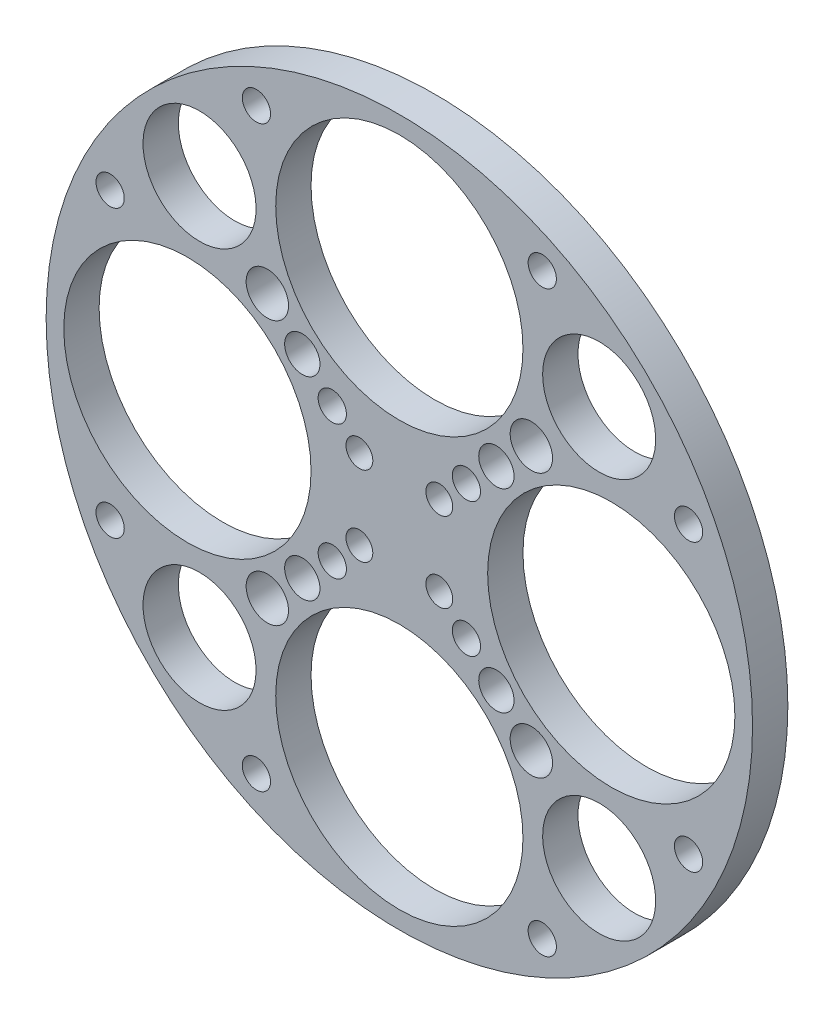
from build123d import *

# Parameters (mm, degrees)
SKETCH1_R           = 50
BOSS_EXTRUDE1_DEPTH = 5
SKETCH2_R           = 1.9
CUT_EXTRUDE1_DEPTH  = 6
CIRPATTERN1_COUNT   = 4
SKETCH3_R           = 17.5
CUT_EXTRUDE2_DEPTH  = 6
CIRPATTERN2_COUNT   = 4
SKETCH4_R           = 8
SKETCH4_R_2         = 3
SKETCH4_R_3         = 2.5
SKETCH4_R_4         = 2
CUT_EXTRUDE3_DEPTH  = 6
CIRPATTERN3_COUNT   = 4


with BuildPart() as part:
    # Sketch1 → Boss-Extrude1 (new body)
    with BuildSketch(Plane.XY):
        Circle(SKETCH1_R)
    extrude(amount=BOSS_EXTRUDE1_DEPTH)

    # Sketch2 → Cut-Extrude1 (cut, through all)
    with BuildSketch(Plane(origin=(0, 0, 0), x_dir=(-1, 0, 0), z_dir=(0, 0, -1))):
        with Locations((-5.656854249, 5.656854249)):
            Circle(SKETCH2_R)
    cut_extrude1 = extrude(amount=-CUT_EXTRUDE1_DEPTH, mode=Mode.SUBTRACT)

    # CirPattern1: Cut-Extrude1 ×4 about axis
    cirpattern1_axis = Axis((0, 0, 0), (0, 0, 1))
    for i in range(1, CIRPATTERN1_COUNT):
        add(cut_extrude1.rotate(cirpattern1_axis, i * 360 / CIRPATTERN1_COUNT), mode=Mode.SUBTRACT)

    # Sketch3 → Cut-Extrude2 (cut, through all)
    with BuildSketch(Plane(origin=(0, 0, 0), x_dir=(-1, 0, 0), z_dir=(0, 0, -1))):
        with Locations((0, 30)):
            Circle(SKETCH3_R)
    cut_extrude2 = extrude(amount=-CUT_EXTRUDE2_DEPTH, mode=Mode.SUBTRACT)

    # CirPattern2: Cut-Extrude2 ×4 about axis
    cirpattern2_axis = Axis((0, 0, 0), (0, 0, 1))
    for i in range(1, CIRPATTERN2_COUNT):
        add(cut_extrude2.rotate(cirpattern2_axis, i * 360 / CIRPATTERN2_COUNT), mode=Mode.SUBTRACT)

    # Sketch4 → Cut-Extrude3 (cut, through all)
    with BuildSketch(Plane(origin=(0, 0, 0), x_dir=(-1, 0, 0), z_dir=(0, 0, -1))):
        with Locations((-28.284271247, 28.284271247)):
            Circle(SKETCH4_R)
        with Locations((-18.686291501, 18.686291501)):
            Circle(SKETCH4_R_2)
        with Locations((-13.736544033, 13.736544033)):
            Circle(SKETCH4_R_3)
        with Locations((-9.493903346, 9.493903346)):
            Circle(SKETCH4_R_4)
        with Locations((-20.231783609, 40.939603832)):
            Circle(SKETCH4_R_4)
        with Locations((-40.939603832, 20.231783609)):
            Circle(SKETCH4_R_4)
    cut_extrude3 = extrude(amount=-CUT_EXTRUDE3_DEPTH, mode=Mode.SUBTRACT)

    # CirPattern3: Cut-Extrude3 ×4 about axis
    cirpattern3_axis = Axis((0, 0, 0), (0, 0, 1))
    for i in range(1, CIRPATTERN3_COUNT):
        add(cut_extrude3.rotate(cirpattern3_axis, i * 360 / CIRPATTERN3_COUNT), mode=Mode.SUBTRACT)


solid = part.part
